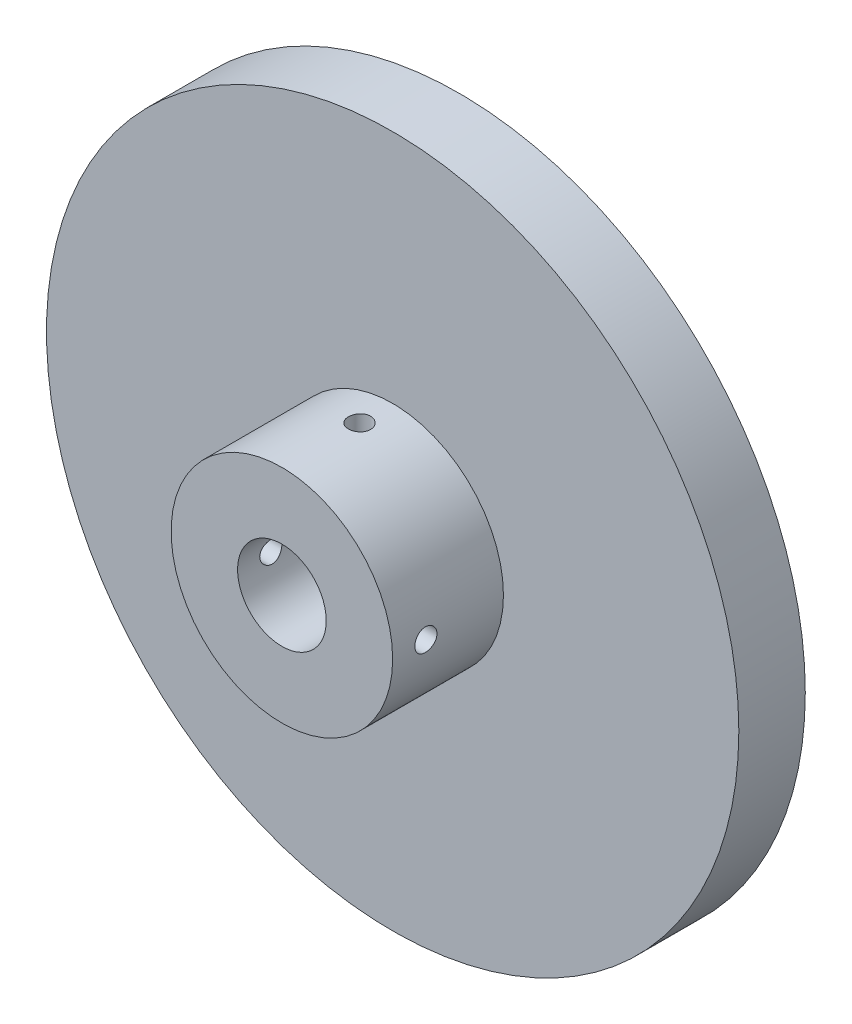
from build123d import *

# Parameters (mm, degrees)
SKETCH_1_R               = 31.25
SKETCH_1_R_2             = 4
EXTRUDE_1_DEPTH          = 6
SKETCH_2_R               = 10
SKETCH_2_R_2             = 4
EXTRUDE_2_DEPTH          = 10
SKETCH_3_R               = 1
CUT_EXTRUDE_1_DEPTH      = 32.25
CUT_EXTRUDE_1_DEPTH_BACK = 32.25
SKETCH_4_R               = 1
CUT_EXTRUDE_2_DEPTH      = 32.25
CUT_EXTRUDE_2_DEPTH_BACK = 32.25


with BuildPart() as part:
    # Эскиз1 → Бобышка-Вытянуть1 (new body)
    with BuildSketch(Plane.XY):
        Circle(SKETCH_1_R)
        Circle(SKETCH_1_R_2, mode=Mode.SUBTRACT)
    extrude(amount=EXTRUDE_1_DEPTH)

    # Эскиз2 → Бобышка-Вытянуть2 (add)
    with BuildSketch(Plane.XY.offset(6)):
        Circle(SKETCH_2_R)
        Circle(SKETCH_2_R_2, mode=Mode.SUBTRACT)
    extrude(amount=EXTRUDE_2_DEPTH)

    # Эскиз3 → Вырез-Вытянуть1 (cut, two sides)
    with BuildSketch(Plane(origin=(0, 0, 0), x_dir=(1, 0, 0), z_dir=(0, 1, 0))) as cut_extrude_1_sk:
        with Locations((0, -9)):
            Circle(SKETCH_3_R)
    extrude(amount=CUT_EXTRUDE_1_DEPTH, mode=Mode.SUBTRACT)
    extrude(cut_extrude_1_sk.sketch, amount=-CUT_EXTRUDE_1_DEPTH_BACK, mode=Mode.SUBTRACT)

    # Эскиз4 → Вырез-Вытянуть2 (cut, two sides)
    with BuildSketch(Plane(origin=(0, 0, 0), x_dir=(0, 0, -1), z_dir=(1, 0, 0))) as cut_extrude_2_sk:
        with Locations((-13, 0)):
            Circle(SKETCH_4_R)
    extrude(amount=CUT_EXTRUDE_2_DEPTH, mode=Mode.SUBTRACT)
    extrude(cut_extrude_2_sk.sketch, amount=-CUT_EXTRUDE_2_DEPTH_BACK, mode=Mode.SUBTRACT)


solid = part.part
